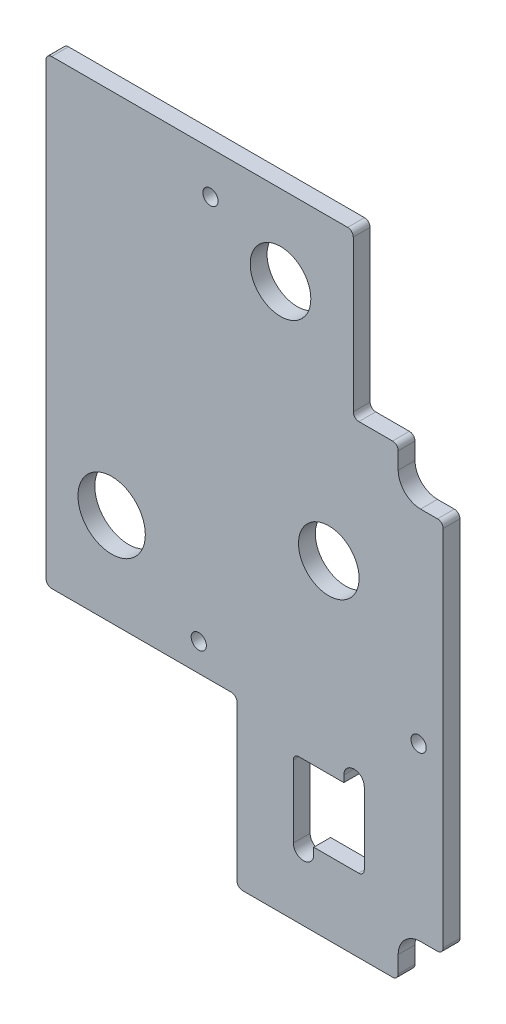
from build123d import *

# Parameters (mm, degrees)
SKETCH3_W             = 20.066
SKETCH3_H             = 20.066
BOSS_EXTRUDE1_DEPTH   = 4.7625
SKETCH6_R             = 8.5725
CUT_EXTRUDE4_DEPTH    = 5.7625
SKETCH61_R            = 8.5725
CUT_EXTRUDE41_DEPTH   = 5.7625
SKETCH62_R            = 9.525
CUT_EXTRUDE42_DEPTH   = 5.7625
F_6_CLEARANCE_HOLE1_D = 4.3053
CUT_EXTRUDE43_REACH   = 6.763
FILLET1_R             = 1.5875


with BuildPart() as part:
    # Sketch3 → Boss-Extrude1 (new body)
    with BuildSketch(Plane.XY):
        with BuildLine():
            Line((-0.5715, -189.484), (41.8465, -189.484))
            ThreePointArc((41.8465, -189.484), (42.969032015, -189.019032015), (43.434, -187.8965))
            Line((43.434, -187.8965), (43.434, -183.134))
            ThreePointArc((43.434, -183.134), (45.293871939, -178.643871939), (49.784, -176.784))
            Line((49.784, -176.784), (54.5465, -176.784))
            ThreePointArc((54.5465, -176.784), (55.669032015, -176.319032015), (56.134, -175.1965))
            Line((56.134, -175.1965), (56.134, -72.4535))
            ThreePointArc((56.134, -72.4535), (55.669032015, -71.330967985), (54.5465, -70.866))
            Line((54.5465, -70.866), (49.784, -70.866))
            ThreePointArc((49.784, -70.866), (45.293871939, -69.006128061), (43.434, -64.516))
            Line((43.434, -64.516), (43.434, -59.7535))
            ThreePointArc((43.434, -59.7535), (42.969032015, -58.630967985), (41.8465, -58.166))
            Line((41.8465, -58.166), (32.3215, -58.166))
            ThreePointArc((32.3215, -58.166), (31.198967985, -57.701032015), (30.734, -56.5785))
            Line((30.734, -56.5785), (30.734, -13.7795))
            ThreePointArc((30.734, -13.7795), (30.269032015, -12.656967985), (29.1465, -12.192))
            Line((29.1465, -12.192), (-54.5465, -12.192))
            ThreePointArc((-54.5465, -12.192), (-55.669032015, -12.656967985), (-56.134, -13.7795))
            Line((-56.134, -13.7795), (-56.134, -140.9065))
            ThreePointArc((-56.134, -140.9065), (-55.669032015, -142.029032015), (-54.5465, -142.494))
            Line((-54.5465, -142.494), (-3.7465, -142.494))
            ThreePointArc((-3.7465, -142.494), (-2.623967985, -142.958967985), (-2.159, -144.0815))
            Line((-2.159, -144.0815), (-2.159, -187.8965))
            ThreePointArc((-2.159, -187.8965), (-1.694032015, -189.019032015), (-0.5715, -189.484))
        make_face()
        with Locations((23.8125, -158.75)):
            Rectangle(SKETCH3_W, SKETCH3_H, mode=Mode.SUBTRACT)
    extrude(amount=BOSS_EXTRUDE1_DEPTH)

    # Sketch6 → Cut-Extrude4 (cut, through all)
    with BuildSketch(Plane(origin=(161.486140968, -518.011138809, 4.7625), x_dir=(1, 0, 0), z_dir=(0, 0, 1))):
        with Locations((-137.673640968, 421.491138809)):
            Circle(SKETCH6_R)
    extrude(amount=-CUT_EXTRUDE4_DEPTH, mode=Mode.SUBTRACT)

    # Sketch61 → Cut-Extrude41 (cut, through all)
    with BuildSketch(Plane(origin=(147.833640968, -456.416138809, 4.7625), x_dir=(1, 0, 0), z_dir=(0, 0, 1))):
        with Locations((-137.673640968, 421.491138809)):
            Circle(SKETCH61_R)
    extrude(amount=-CUT_EXTRUDE41_DEPTH, mode=Mode.SUBTRACT)

    # Sketch62 → Cut-Extrude42 (cut, through all)
    with BuildSketch(Plane.XY.offset(4.7625)):
        with Locations((-37.592, -116.078)):
            Circle(SKETCH62_R)
    extrude(amount=-CUT_EXTRUDE42_DEPTH, mode=Mode.SUBTRACT)

    # #6 Clearance Hole1 (through all)
    with Locations(Plane(origin=(36.5125, -265.1125, 6.35), x_dir=(-1, 0, 0), z_dir=(0, 0, 1))):
        with Locations((49.4665, -130.4925), (-12.7, -136.525), (46.1645, -240.9825)):
            Hole(F_6_CLEARANCE_HOLE1_D / 2)

    # Sketch67 → Cut-Extrude43 (cut, up to next)
    with BuildSketch(Plane(origin=(0, 0, 0), x_dir=(-1, 0, 0), z_dir=(0, 0, -1)), mode=Mode.PRIVATE) as cut_extrude43_sk1:
        with BuildLine():
            Line((-19.558, -170.65625), (-19.558, -167.48125))
            ThreePointArc((-19.558, -167.48125), (-16.66875, -164.592), (-13.7795, -167.48125))
            Line((-13.7795, -167.48125), (-13.7795, -170.65625))
            ThreePointArc((-13.7795, -170.65625), (-16.66875, -173.5455), (-19.558, -170.65625))
        make_face()
    cut_extrude43_tool1 = extrude(cut_extrude43_sk1.sketch, amount=-CUT_EXTRUDE43_REACH, mode=Mode.PRIVATE) & part.part
    add(cut_extrude43_tool1.solids().sort_by_distance((16.66875, -169.06875, 0))[0], mode=Mode.SUBTRACT)
    # Sketch67 → Cut-Extrude43 (cut, up to next)
    with BuildSketch(Plane(origin=(0, 0, 0), x_dir=(-1, 0, 0), z_dir=(0, 0, -1)), mode=Mode.PRIVATE) as cut_extrude43_sk2:
        with BuildLine():
            Line((-28.067, -146.84375), (-28.067, -150.01875))
            ThreePointArc((-28.067, -150.01875), (-30.95625, -152.908), (-33.8455, -150.01875))
            Line((-33.8455, -150.01875), (-33.8455, -146.84375))
            ThreePointArc((-33.8455, -146.84375), (-30.95625, -143.9545), (-28.067, -146.84375))
        make_face()
    cut_extrude43_tool2 = extrude(cut_extrude43_sk2.sketch, amount=-CUT_EXTRUDE43_REACH, mode=Mode.PRIVATE) & part.part
    add(cut_extrude43_tool2.solids().sort_by_distance((30.95625, -148.43125, 0))[0], mode=Mode.SUBTRACT)

    # Fillet1
    fillet1_edges = [part.edges().sort_by_distance(p)[0] for p in [
        (33.8455, -168.783, 2.38125),
        (13.7795, -148.717, 2.38125),
    ]]
    fillet(fillet1_edges, radius=FILLET1_R)


solid = part.part
